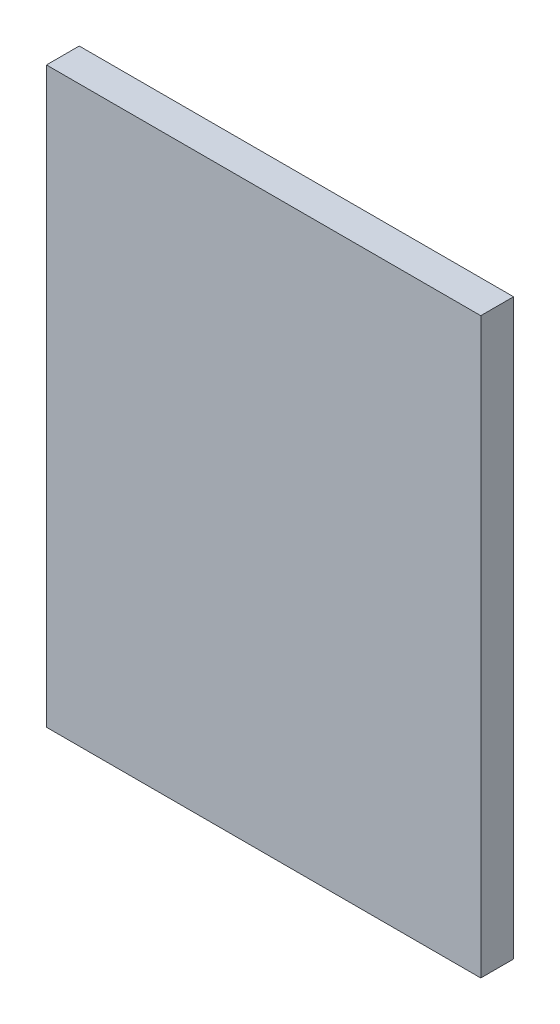
from build123d import *

# Parameters (mm, degrees)
SKETCH1_W           = 26.5
SKETCH1_H           = 35
BOSS_EXTRUDE1_DEPTH = 2


with BuildPart() as part:
    # Sketch1 → Boss-Extrude1 (new body)
    with BuildSketch(Plane.XY):
        Rectangle(SKETCH1_W, SKETCH1_H)
    extrude(amount=BOSS_EXTRUDE1_DEPTH)


solid = part.part
